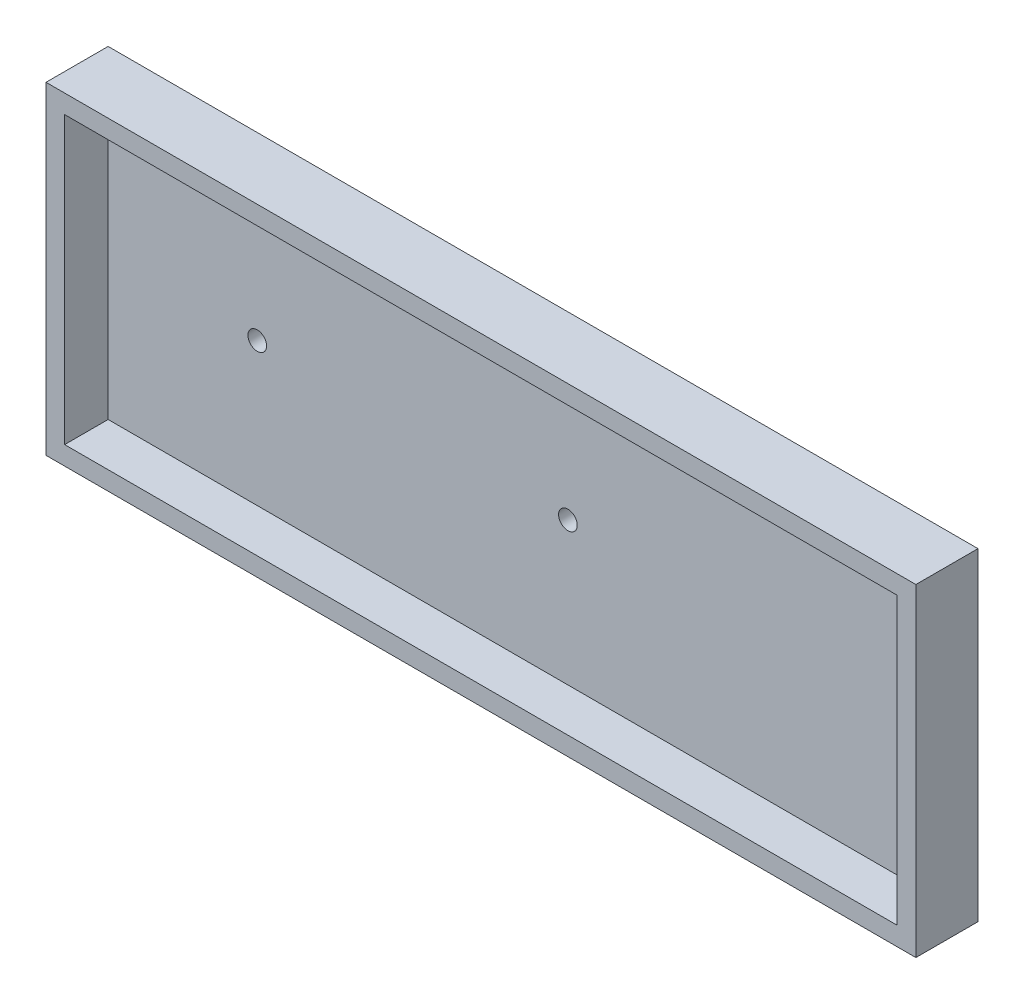
from build123d import *

# Parameters (mm, degrees)
SKETCH1_W           = 70
SKETCH1_H           = 26
BOSS_EXTRUDE1_DEPTH = 5
SHELL1_T            = -1.5
SKETCH2_R           = 0.75
CUT_EXTRUDE1_DEPTH  = 2.5


with BuildPart() as part:
    # Sketch1 → Boss-Extrude1 (new body)
    with BuildSketch(Plane.XY):
        Rectangle(SKETCH1_W, SKETCH1_H)
    extrude(amount=BOSS_EXTRUDE1_DEPTH)

    # Shell1
    shell1_openings = [part.faces().sort_by_distance(p)[0] for p in [
        (0, 0, 5),
    ]]
    offset(amount=SHELL1_T, openings=shell1_openings, kind=Kind.INTERSECTION)

    # Sketch2 → Cut-Extrude1 (cut, through all)
    with BuildSketch(Plane.XY.offset(1.5)):
        with Locations((-21.5, 0)):
            Circle(SKETCH2_R)
        with Locations((3.5, 0)):
            Circle(SKETCH2_R)
    extrude(amount=-CUT_EXTRUDE1_DEPTH, mode=Mode.SUBTRACT)


solid = part.part
